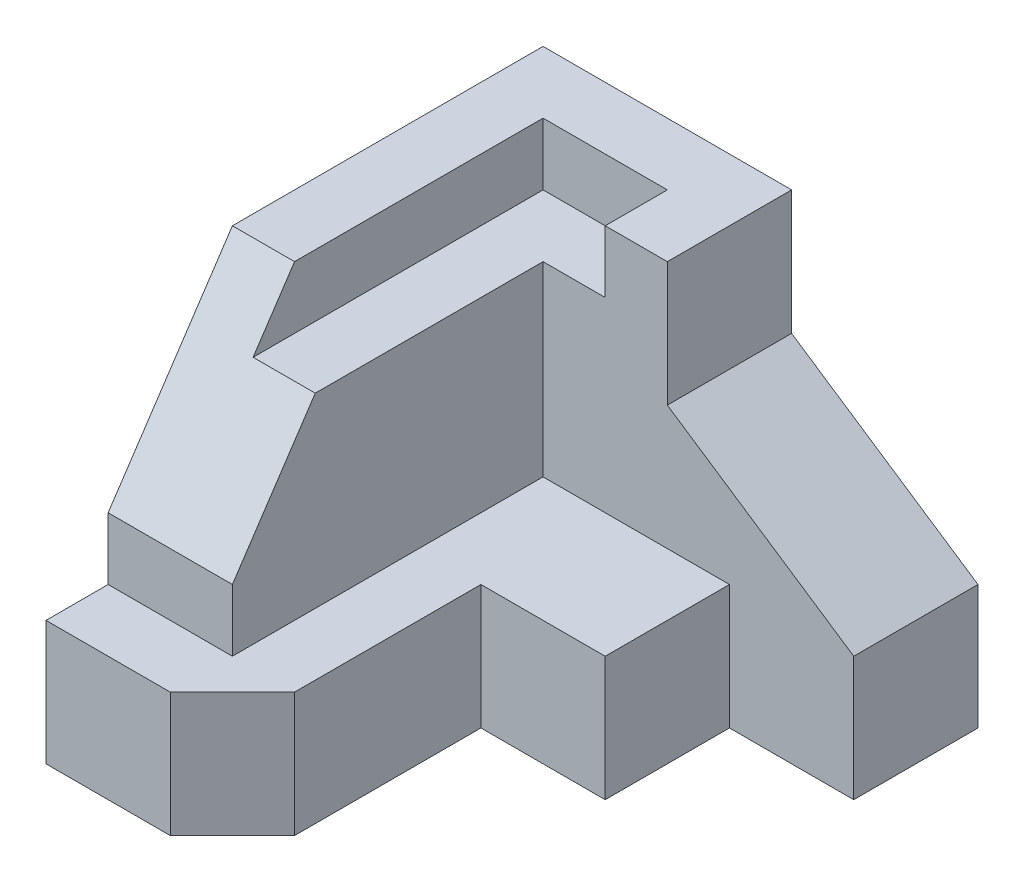
from build123d import *

# Parameters (mm, degrees)
SKETCH1_W           = 7
SKETCH1_H           = 6
BOSS_EXTRUDE2_DEPTH = 8
CUT_EXTRUDE2_DEPTH  = 7
CUT_EXTRUDE3_DEPTH  = 4
CUT_EXTRUDE4_DEPTH  = 2
CUT_EXTRUDE5_DEPTH  = 1
SKETCH10_W          = 2
SKETCH10_H          = 3.605551276
CUT_EXTRUDE6_DEPTH  = 3.496150883


with BuildPart() as part:
    # Sketch1 → Boss-Extrude2 (new body)
    with BuildSketch(Plane.XY):
        Rectangle(SKETCH1_W, SKETCH1_H)
    extrude(amount=BOSS_EXTRUDE2_DEPTH)

    # Sketch4 → Cut-Extrude2 (cut, through all)
    with BuildSketch(Plane(origin=(0, 3, 0), x_dir=(1, 0, 0), z_dir=(0, 1, 0))):
        Polygon((3.5, -2), (1.5, -2), (1.5, -4), (-0.5, -4), (-0.5, -7), (-1.5, -8), (3.5, -8), align=None)
    extrude(amount=-CUT_EXTRUDE2_DEPTH, mode=Mode.SUBTRACT)

    # Sketch5 → Cut-Extrude3 (cut)
    with BuildSketch(Plane(origin=(0, 3, 0), x_dir=(1, 0, 0), z_dir=(0, 1, 0))):
        Polygon((1.5, -4), (1.5, -2), (-1.5, -2), (-1.5, -7), (-3.5, -7), (-3.5, -8), (-1.5, -8), (-0.5, -7), (-0.5, -4), align=None)
    extrude(amount=-CUT_EXTRUDE3_DEPTH, mode=Mode.SUBTRACT)

    # Sketch6 → Cut-Extrude4 (cut)
    with BuildSketch(Plane(origin=(0, 0, 0), x_dir=(-1, 0, 0), z_dir=(0, 0, -1))):
        Polygon((-3.5, -1), (-0.5, 1), (-0.5, 3), (-3.5, 3), align=None)
    extrude(amount=-CUT_EXTRUDE4_DEPTH, mode=Mode.SUBTRACT)

    # Sketch7 → Cut-Extrude5 (cut)
    with BuildSketch(Plane(origin=(0, 3, 0), x_dir=(1, 0, 0), z_dir=(0, 1, 0))):
        Polygon((-0.5, -2), (-0.5, -1), (-2.5, -1), (-2.5, -6), (-1.5, -6), (-1.5, -2), align=None)
    extrude(amount=-CUT_EXTRUDE5_DEPTH, mode=Mode.SUBTRACT)

    # Sketch10 → Cut-Extrude6 (cut, through all)
    with BuildSketch(Plane(origin=(0, 3.230769231, 4.846153846), x_dir=(-1, 0, 0), z_dir=(0, -0.554700196, -0.832050294))):
        with Locations((2.5, -2.080125736)):
            Rectangle(SKETCH10_W, SKETCH10_H)
    extrude(amount=-CUT_EXTRUDE6_DEPTH, mode=Mode.SUBTRACT)


solid = part.part
